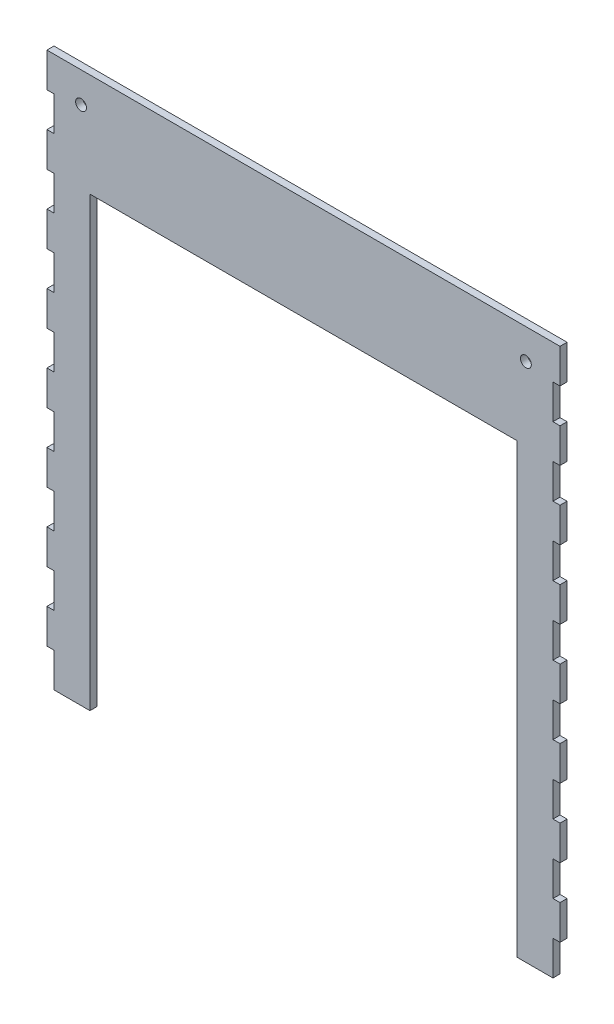
from build123d import *

# Parameters (mm, degrees)
SKETCH1_R           = 4
BOSS_EXTRUDE1_DEPTH = 5.207


with BuildPart() as part:
    # Sketch1 → Boss-Extrude1 (new body)
    with BuildSketch(Plane.XY):
        Polygon((-184.15, 25.4), (-184.15, 0), (-157.607, 0), (-157.607, 330.2), (157.607, 330.2), (157.607, 0), (184.15, 0), (184.15, 25.4), (189.357, 25.4), (189.357, 50.8), (184.15, 50.8), (184.15, 76.2), (189.357, 76.2), (189.357, 101.6), (184.15, 101.6), (184.15, 127), (189.357, 127), (189.357, 152.4), (184.15, 152.4), (184.15, 177.8), (189.357, 177.8), (189.357, 203.2), (184.15, 203.2), (184.15, 228.6), (189.357, 228.6), (189.357, 254), (184.15, 254), (184.15, 279.4), (189.357, 279.4), (189.357, 304.8), (184.15, 304.8), (184.15, 330.2), (189.357, 330.2), (189.357, 355.6), (184.15, 355.6), (184.15, 381), (189.357, 381), (189.357, 406.4), (-189.357, 406.4), (-189.357, 381), (-184.15, 381), (-184.15, 355.6), (-189.357, 355.6), (-189.357, 330.2), (-184.15, 330.2), (-184.15, 304.8), (-189.357, 304.8), (-189.357, 279.4), (-184.15, 279.4), (-184.15, 254), (-189.357, 254), (-189.357, 228.6), (-184.15, 228.6), (-184.15, 203.2), (-189.357, 203.2), (-189.357, 177.8), (-184.15, 177.8), (-184.15, 152.4), (-189.357, 152.4), (-189.357, 127), (-184.15, 127), (-184.15, 101.6), (-189.357, 101.6), (-189.357, 76.2), (-184.15, 76.2), (-184.15, 50.8), (-189.357, 50.8), (-189.357, 25.4), align=None)
        with Locations((-164.150000122, 384.05)):
            Circle(SKETCH1_R, mode=Mode.SUBTRACT)
        with Locations((164.1499892, 384.05)):
            Circle(SKETCH1_R, mode=Mode.SUBTRACT)
    extrude(amount=BOSS_EXTRUDE1_DEPTH)


solid = part.part
